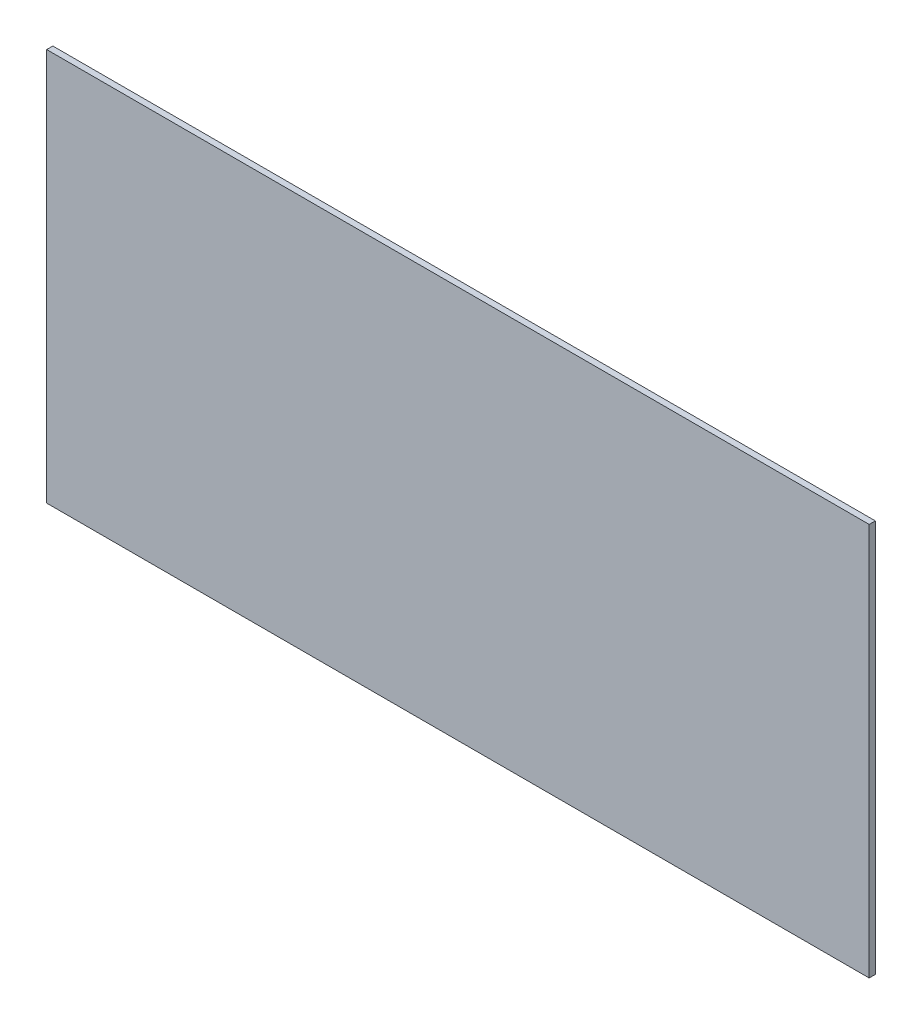
from build123d import *

# Parameters (mm, degrees)
SZKIC1_W                    = 1340
SZKIC1_H                    = 640
DODANIE_WYCI_GNI_CIE1_DEPTH = 10


with BuildPart() as part:
    # Szkic1 → Dodanie-wyciągnięcie1 (new body)
    with BuildSketch(Plane.XY):
        with Locations((65.699954567, 1.842900302)):
            Rectangle(SZKIC1_W, SZKIC1_H)
    extrude(amount=DODANIE_WYCI_GNI_CIE1_DEPTH)


solid = part.part
